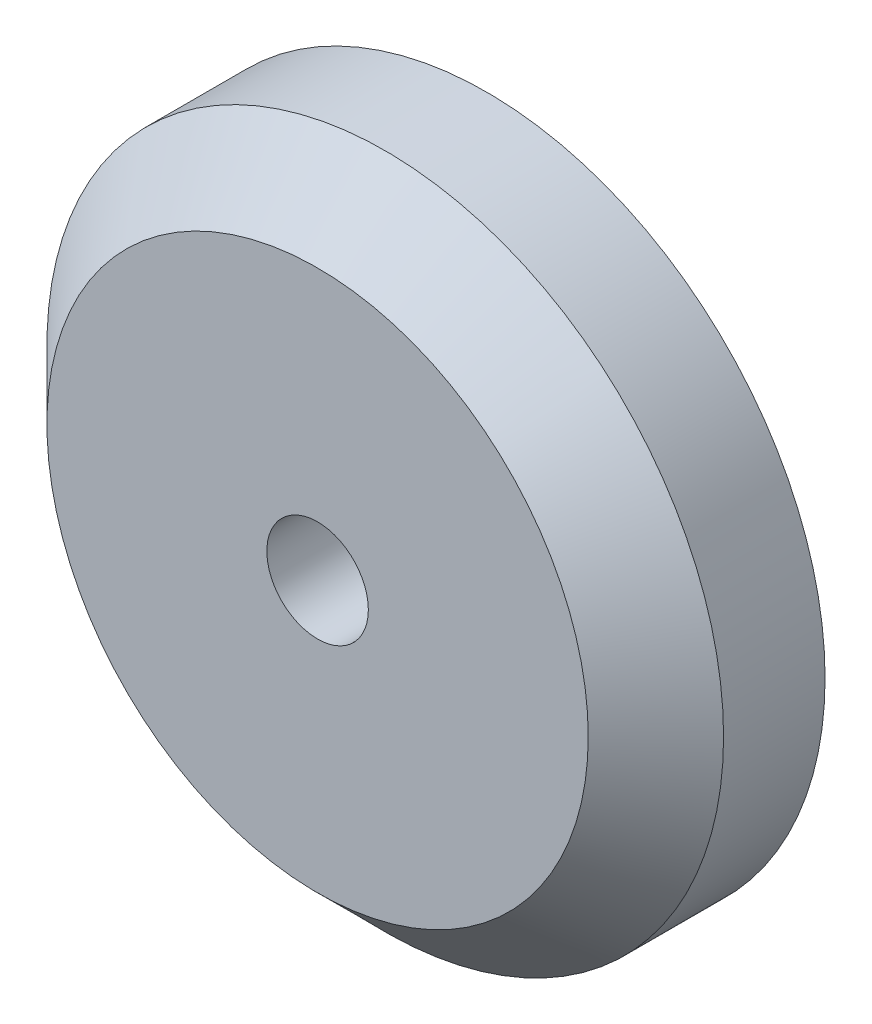
from build123d import *

# Parameters (mm, degrees)
SKETCH1_R           = 10
BOSS_EXTRUDE1_DEPTH = 5
CHAMFER1_SIZE       = 2
SKETCH2_R           = 1.5
CUT_EXTRUDE1_DEPTH  = 5


with BuildPart() as part:
    # Sketch1 → Boss-Extrude1 (new body)
    with BuildSketch(Plane.XY):
        Circle(SKETCH1_R)
    extrude(amount=BOSS_EXTRUDE1_DEPTH)

    # Chamfer1
    chamfer1_edges = [part.edges().sort_by_distance(p)[0] for p in [
        (-10, 0, 5),
    ]]
    chamfer(chamfer1_edges, length=CHAMFER1_SIZE)

    # Sketch2 → Cut-Extrude1 (cut)
    with BuildSketch(Plane.XY.offset(5)):
        Circle(SKETCH2_R)
    extrude(amount=-CUT_EXTRUDE1_DEPTH, mode=Mode.SUBTRACT)


solid = part.part
